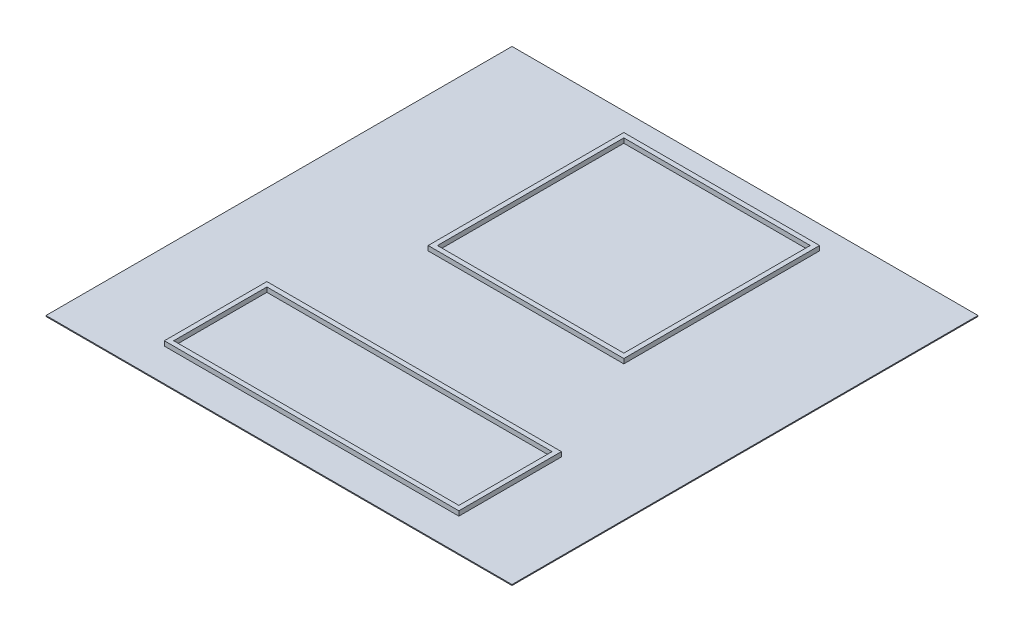
from build123d import *

# Parameters (mm, degrees)
SKETCH1_W           = 5000
SKETCH1_H           = 5000
BOSS_EXTRUDE1_DEPTH = 10
SKETCH2_W           = 2100
SKETCH2_H           = 2100
SKETCH2_W_2         = 2000
SKETCH2_H_2         = 2000
SKETCH2_W_3         = 3160
SKETCH2_H_3         = 1100
SKETCH2_W_4         = 3060
SKETCH2_H_4         = 1000
BOSS_EXTRUDE2_DEPTH = 50


with BuildPart() as part:
    # Sketch1 → Boss-Extrude1 (new body)
    with BuildSketch(Plane(origin=(0, 0, 0), x_dir=(1, 0, 0), z_dir=(0, 1, 0))):
        with Locations((2500, -2500)):
            Rectangle(SKETCH1_W, SKETCH1_H)
    extrude(amount=BOSS_EXTRUDE1_DEPTH)

    # Sketch2 → Boss-Extrude2 (add)
    with BuildSketch(Plane(origin=(0, 10, 0), x_dir=(1, 0, 0), z_dir=(0, 1, 0))):
        with Locations((2500, -1300)):
            Rectangle(SKETCH2_W, SKETCH2_H)
        with Locations((2500, -1300)):
            Rectangle(SKETCH2_W_2, SKETCH2_H_2, mode=Mode.SUBTRACT)
        with Locations((2500, -4100)):
            Rectangle(SKETCH2_W_3, SKETCH2_H_3)
        with Locations((2500, -4100)):
            Rectangle(SKETCH2_W_4, SKETCH2_H_4, mode=Mode.SUBTRACT)
    extrude(amount=BOSS_EXTRUDE2_DEPTH)


solid = part.part
